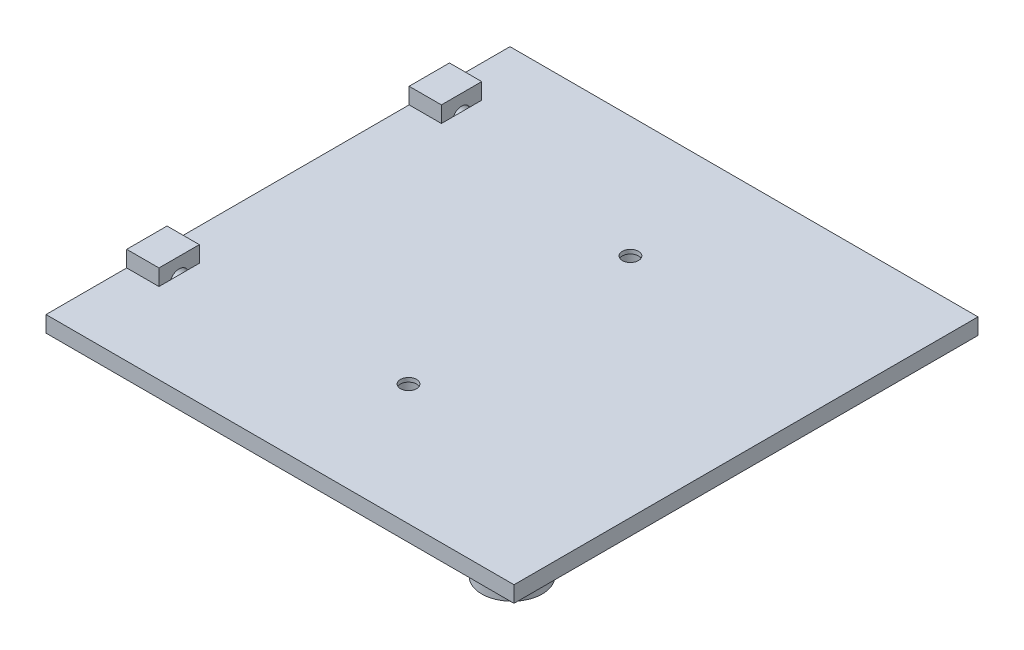
from build123d import *

# Parameters (mm, degrees)
SKETCH1_W               = 116
SKETCH1_H               = 115
BOSS_EXTRUDE1_DEPTH     = 4
SKETCH2_R               = 7.5
SKETCH2_R_2             = 5
BOSS_EXTRUDE2_DEPTH     = 2.5
SKETCH3_W               = 10
SKETCH3_H               = 4
BOSS_EXTRUDE3_DEPTH     = 8
SKETCH6_R               = 2.225609416
SKETCH6_R_2             = 2.302524441
CUT_EXTRUDE2_DEPTH      = 8
SKETCH7_R               = 5
BOSS_EXTRUDE5_DEPTH     = 3
SKETCH9_R               = 2
CUT_EXTRUDE3_DEPTH      = 5
CUT_EXTRUDE3_DEPTH_BACK = 8
SKETCH10_R              = 3.5
CUT_EXTRUDE5_DEPTH      = 3


with BuildPart() as part:
    # Sketch1 → Boss-Extrude1 (new body)
    with BuildSketch(Plane(origin=(0, 0, 0), x_dir=(1, 0, 0), z_dir=(0, 1, 0))):
        with Locations((-35.28313253, -23.102409639)):
            Rectangle(SKETCH1_W, SKETCH1_H)
    extrude(amount=BOSS_EXTRUDE1_DEPTH)

    # Sketch2 → Boss-Extrude2 (add)
    with BuildSketch(Plane(origin=(0, 0, 0), x_dir=(1, 0, 0), z_dir=(0, 1, 0))):
        with Locations((14.21686747, -72.602409639)):
            Circle(SKETCH2_R)
        with Locations((14.21686747, -72.602409639)):
            Circle(SKETCH2_R_2, mode=Mode.SUBTRACT)
    extrude(amount=-BOSS_EXTRUDE2_DEPTH)

    # Sketch3 → Boss-Extrude3 (add)
    with BuildSketch(Plane.ZY.offset(93.28313253)):
        with Locations((-14.397590361, 6)):
            Rectangle(SKETCH3_W, SKETCH3_H)
        with Locations((55.602409639, 6)):
            Rectangle(SKETCH3_W, SKETCH3_H)
    extrude(amount=-BOSS_EXTRUDE3_DEPTH)

    # Sketch6 → Cut-Extrude2 (cut)
    with BuildSketch(Plane.ZY.offset(93.28313253)):
        with Locations((-14.397590361, 3)):
            Circle(SKETCH6_R)
        with Locations((55.602409639, 3)):
            Circle(SKETCH6_R_2)
    extrude(amount=-CUT_EXTRUDE2_DEPTH, mode=Mode.SUBTRACT)

    # Sketch7 → Boss-Extrude5 (add)
    with BuildSketch(Plane.XZ):
        with Locations((2.71686747, -14.397590361)):
            Circle(SKETCH7_R)
    extrude(amount=BOSS_EXTRUDE5_DEPTH)

    # Sketch9 → Cut-Extrude3 (cut, two sides)
    with BuildSketch(Plane(origin=(0, 4, 0), x_dir=(1, 0, 0), z_dir=(0, 1, 0))) as cut_extrude3_sk:
        with Locations((-33.429640785, 4.397590361)):
            Circle(SKETCH9_R)
        with Locations((-33.429640785, -50.602409639)):
            Circle(SKETCH9_R)
    extrude(amount=CUT_EXTRUDE3_DEPTH, mode=Mode.SUBTRACT)
    extrude(cut_extrude3_sk.sketch, amount=-CUT_EXTRUDE3_DEPTH_BACK, mode=Mode.SUBTRACT)

    # Sketch10 → Cut-Extrude5 (cut)
    with BuildSketch(Plane.XZ):
        with Locations((-33.429640785, -4.397590361)):
            Circle(SKETCH10_R)
        with Locations((-33.429640785, 50.602409639)):
            Circle(SKETCH10_R)
    extrude(amount=-CUT_EXTRUDE5_DEPTH, mode=Mode.SUBTRACT)


solid = part.part
